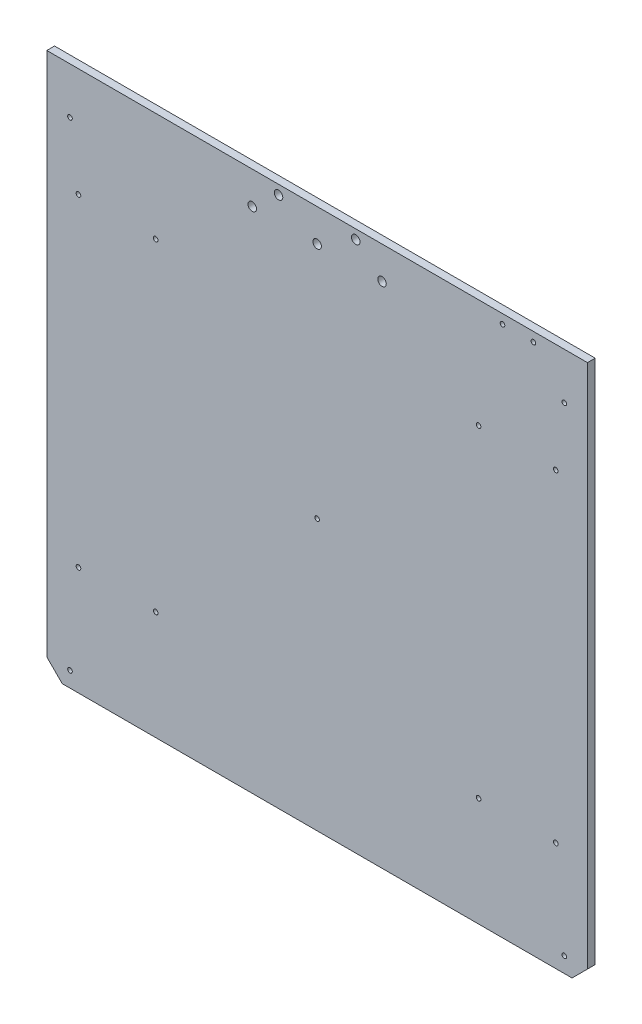
from build123d import *

# Parameters (mm, degrees)
SCHIZZO13_R                  = 1.5
SCHIZZO13_R_2                = 2.75
ESTRUSIONE_ESTRUSIONE2_DEPTH = 5


with BuildPart() as part:
    # Schizzo13 → Estrusione-Estrusione2 (new body)
    with BuildSketch(Plane.XY):
        Polygon((10, 0), (340, 0), (350, 10), (350, 350), (0, 350), (0, 10), align=None)
        with Locations((15, 320)):
            Circle(SCHIZZO13_R, mode=Mode.SUBTRACT)
        with Locations((20.5, 279.5)):
            Circle(SCHIZZO13_R, mode=Mode.SUBTRACT)
        with Locations((70.5, 279.5)):
            Circle(SCHIZZO13_R, mode=Mode.SUBTRACT)
        with Locations((175, 175)):
            Circle(SCHIZZO13_R, mode=Mode.SUBTRACT)
        with Locations((20.5, 70.5)):
            Circle(SCHIZZO13_R, mode=Mode.SUBTRACT)
        with Locations((200, 344)):
            Circle(SCHIZZO13_R_2, mode=Mode.SUBTRACT)
        with Locations((150, 344)):
            Circle(SCHIZZO13_R_2, mode=Mode.SUBTRACT)
        with Locations((175, 329)):
            Circle(SCHIZZO13_R_2, mode=Mode.SUBTRACT)
        with Locations((217, 329)):
            Circle(SCHIZZO13_R_2, mode=Mode.SUBTRACT)
        with Locations((133, 329)):
            Circle(SCHIZZO13_R_2, mode=Mode.SUBTRACT)
        with Locations((70.5, 70.5)):
            Circle(SCHIZZO13_R, mode=Mode.SUBTRACT)
        with Locations((279.5, 70.5)):
            Circle(SCHIZZO13_R, mode=Mode.SUBTRACT)
        with Locations((329.5, 70.5)):
            Circle(SCHIZZO13_R, mode=Mode.SUBTRACT)
        with Locations((335, 10)):
            Circle(SCHIZZO13_R, mode=Mode.SUBTRACT)
        with Locations((15, 10)):
            Circle(SCHIZZO13_R, mode=Mode.SUBTRACT)
        with Locations((279.5, 279.5)):
            Circle(SCHIZZO13_R, mode=Mode.SUBTRACT)
        with Locations((329.5, 279.5)):
            Circle(SCHIZZO13_R, mode=Mode.SUBTRACT)
        with Locations((335, 320)):
            Circle(SCHIZZO13_R, mode=Mode.SUBTRACT)
        with Locations((295, 344)):
            Circle(SCHIZZO13_R, mode=Mode.SUBTRACT)
        with Locations((315, 344)):
            Circle(SCHIZZO13_R, mode=Mode.SUBTRACT)
    extrude(amount=-ESTRUSIONE_ESTRUSIONE2_DEPTH)


solid = part.part
